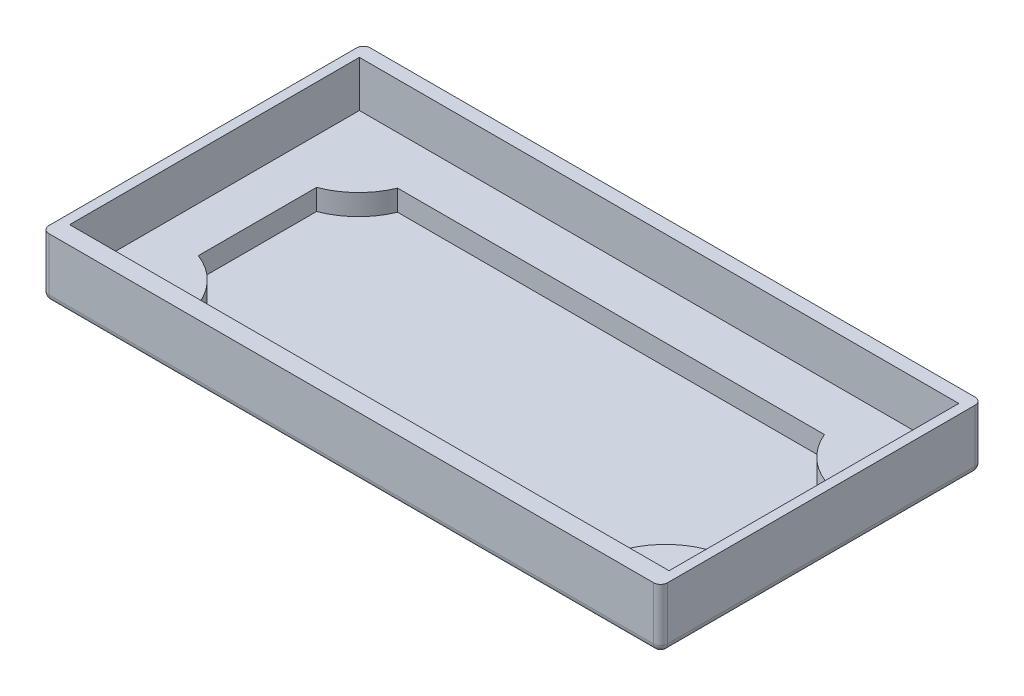
from build123d import *

# Parameters (mm, degrees)
TOP_COVER_SKETCH_01_W       = 44.37
TOP_COVER_SKETCH_01_H       = 23.06
TOP_COVER_EXT_SHAPE_DEPTH   = 4.3
SALIENTE_EXTRUIR1_DEPTH     = 1.5
VACIADO1_T                  = -1
VACIADO1_THICKNESS_2_FACE_W = 21.06
VACIADO1_THICKNESS_2_FACE_H = 3.3
VACIADO1_THICKNESS_2_DEPTH  = 0.31
VACIADO1_THICKNESS_3_FACE_W = 21.06
VACIADO1_THICKNESS_3_FACE_H = 3.3
VACIADO1_THICKNESS_3_DEPTH  = 0.31
VACIADO1_THICKNESS_4_FACE_W = 42.99
VACIADO1_THICKNESS_4_FACE_H = 3.3
VACIADO1_THICKNESS_4_DEPTH  = 0.02
VACIADO1_THICKNESS_5_FACE_W = 42.99
VACIADO1_THICKNESS_5_FACE_H = 3.3
VACIADO1_THICKNESS_5_DEPTH  = 0.3
CROQUIS1_R                  = 3.25
CORTAR_EXTRUIR1_DEPTH       = 0.7
CROQUIS1_5_R                = 5
CROQUIS1_5_R_2              = 3.25
CORTAR_EXTRUIR2_DEPTH       = 0.5
CROQUIS2_R                  = 3
SALIENTE_EXTRUIR2_DEPTH     = 4.7
REDONDEO1_R                 = 0.5


with BuildPart() as part:
    # Top-cover-sketch-01 → Top-cover-ext-shape (new body)
    with BuildSketch(Plane(origin=(0, 0, 0), x_dir=(1, 0, 0), z_dir=(0, 1, 0))):
        Rectangle(TOP_COVER_SKETCH_01_W, TOP_COVER_SKETCH_01_H)
    extrude(amount=TOP_COVER_EXT_SHAPE_DEPTH)

    # Top-cover-sketch-01_18 → Saliente-Extruir1 (add)
    with BuildSketch(Plane(origin=(0, 0, 0), x_dir=(1, 0, 0), z_dir=(0, 1, 0))):
        with BuildLine():
            Line((16.025784389, 8.1), (-16.025784389, 8.1))
            ThreePointArc((-16.025784389, 8.1), (-17.190017633, 6.076280801), (-19.255, 4.986911136))
            Line((-19.255, 4.986911136), (-19.255, -4.986911136))
            ThreePointArc((-19.255, -4.986911136), (-17.190017633, -6.076280801), (-16.025784389, -8.1))
            Line((-16.025784389, -8.1), (16.025784389, -8.1))
            ThreePointArc((16.025784389, -8.1), (17.190017633, -6.076280801), (19.255, -4.986911136))
            Line((19.255, -4.986911136), (19.255, 4.986911136))
            ThreePointArc((19.255, 4.986911136), (17.190017633, 6.076280801), (16.025784389, 8.1))
        make_face()
    extrude(amount=-SALIENTE_EXTRUIR1_DEPTH)

    # Vaciado1
    vaciado1_openings = [part.faces().sort_by_distance(p)[0] for p in [
        (0, 4.3, 0),
    ]]
    offset(amount=VACIADO1_T, openings=vaciado1_openings, kind=Kind.INTERSECTION)

    # Vaciado1 thickness 2 face (on inner face of the shell) → Vaciado1 thickness 2 (cut)
    with BuildSketch(Plane(origin=(-21.185, 2.65, 0), x_dir=(0, 0, -1), z_dir=(-1, 0, 0))):
        Rectangle(VACIADO1_THICKNESS_2_FACE_W, VACIADO1_THICKNESS_2_FACE_H)
    extrude(amount=VACIADO1_THICKNESS_2_DEPTH, mode=Mode.SUBTRACT)

    # Vaciado1 thickness 3 face (on inner face of the shell) → Vaciado1 thickness 3 (cut)
    with BuildSketch(Plane(origin=(21.185, 2.65, 0), x_dir=(0, 0, 1), z_dir=(1, 0, 0))):
        Rectangle(VACIADO1_THICKNESS_3_FACE_W, VACIADO1_THICKNESS_3_FACE_H)
    extrude(amount=VACIADO1_THICKNESS_3_DEPTH, mode=Mode.SUBTRACT)

    # Vaciado1 thickness 4 face (on inner face of the shell) → Vaciado1 thickness 4 (cut)
    with BuildSketch(Plane(origin=(0, 2.65, -10.53), x_dir=(-1, 0, 0), z_dir=(0, 0, -1))):
        Rectangle(VACIADO1_THICKNESS_4_FACE_W, VACIADO1_THICKNESS_4_FACE_H)
    extrude(amount=VACIADO1_THICKNESS_4_DEPTH, mode=Mode.SUBTRACT)

    # Vaciado1 thickness 5 face (on inner face of the shell) → Vaciado1 thickness 5 (add)
    with BuildSketch(Plane(origin=(0, 2.65, 10.53), x_dir=(1, 0, 0), z_dir=(0, 0, 1))):
        Rectangle(VACIADO1_THICKNESS_5_FACE_W, VACIADO1_THICKNESS_5_FACE_H)
    extrude(amount=-VACIADO1_THICKNESS_5_DEPTH)

    # Croquis1 → Cortar-Extruir1 (cut)
    with BuildSketch(Plane.XZ.offset(1.5)):
        with Locations((-11.878900962, 0)):
            Circle(CROQUIS1_R)
    extrude(amount=-CORTAR_EXTRUIR1_DEPTH, mode=Mode.SUBTRACT)

    # Croquis1_5 → Cortar-Extruir2 (cut)
    with BuildSketch(Plane.XZ.offset(1.5)):
        with Locations((-11.878900962, 0)):
            Circle(CROQUIS1_5_R)
        with Locations((-11.878900962, 0)):
            Circle(CROQUIS1_5_R_2, mode=Mode.SUBTRACT)
    extrude(amount=-CORTAR_EXTRUIR2_DEPTH, mode=Mode.SUBTRACT)

    # Croquis2 → Saliente-Extruir2 (add)
    with BuildSketch(Plane.XZ.offset(0.8)):
        with Locations((-11.878900962, 0)):
            Circle(CROQUIS2_R)
    extrude(amount=SALIENTE_EXTRUIR2_DEPTH)

    # Redondeo1
    redondeo1_edges = [part.edges().sort_by_distance(p)[0] for p in [
        (22.185, 2.15, 11.53),
        (22.185, 2.15, -11.53),
        (-22.185, 0, 0),
        (22.185, 0, 0),
        (0, 0, 11.53),
        (-22.185, 2.15, 11.53),
        (-22.185, 2.15, -11.53),
        (0, 0, -11.53),
    ]]
    fillet(redondeo1_edges, radius=REDONDEO1_R)


solid = part.part
